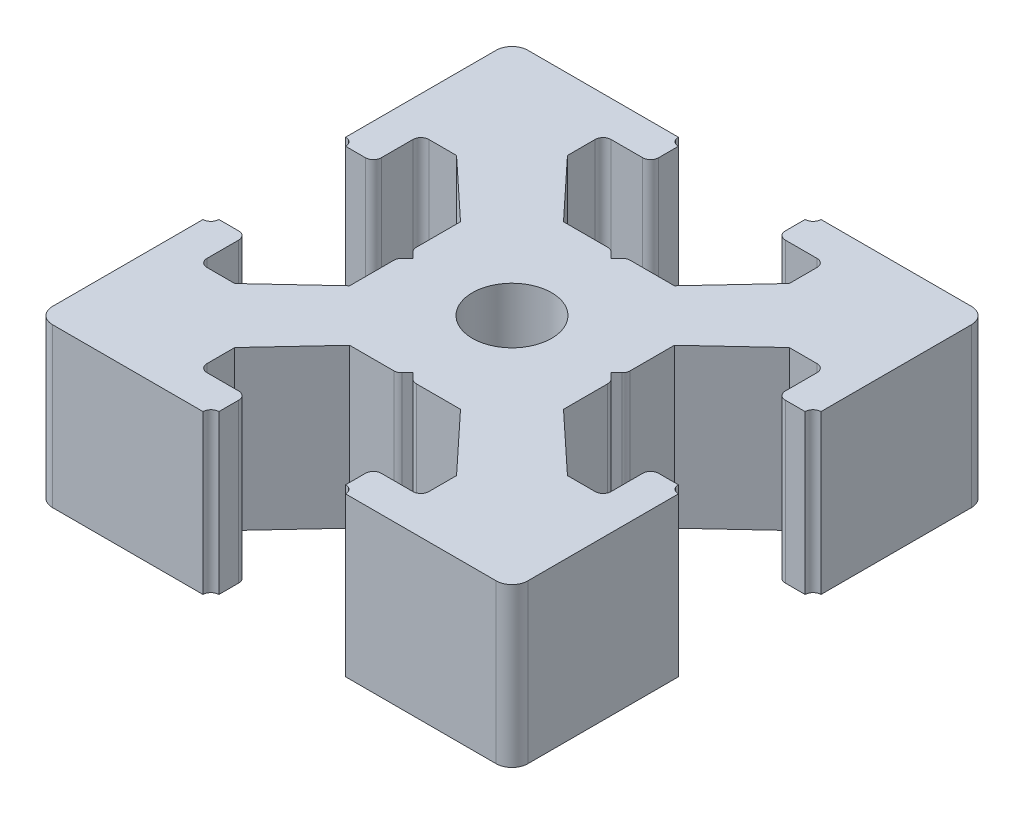
from build123d import *

# Parameters (mm, degrees)
BOSS_EXTRUDE1_DEPTH = 10
FILLET1_R           = 1
SKETCH4_R           = 2.5
CUT_EXTRUDE1_DEPTH  = 11
FILLET2_R           = 0.5


with BuildPart() as part:
    # Sketch3 → Boss-Extrude1 (new body)
    with BuildSketch(Plane(origin=(0, 0, 0), x_dir=(1, 0, 0), z_dir=(0, 1, 0))):
        with BuildLine():
            Line((11, 27.75), (11, 29.5))
            ThreePointArc((11, 29.5), (10.646446609, 29.646446609), (10.5, 30))
            Line((10.5, 30), (0, 30))
            Line((0, 30), (0, 19.5))
            ThreePointArc((0, 19.5), (0.353553391, 19.353553391), (0.5, 19))
            Line((0.5, 19), (2.25, 19))
            Line((2.25, 19), (2.25, 22))
            Line((2.25, 22), (4.5, 22))
            Line((4.5, 22), (8.25, 18.5))
            Line((8.25, 18.5), (8.25, 15.5))
            Line((8.25, 15.5), (8.75, 15))
            Line((8.75, 15), (8.25, 14.5))
            Line((8.25, 14.5), (8.25, 11.5))
            Line((8.25, 11.5), (4.5, 8))
            Line((4.5, 8), (2.25, 8))
            Line((2.25, 8), (2.25, 11))
            Line((2.25, 11), (0.5, 11))
            ThreePointArc((0.5, 11), (0.353553391, 10.646446609), (0, 10.5))
            Line((0, 10.5), (0, 0))
            Line((0, 0), (10.5, 0))
            ThreePointArc((10.5, 0), (10.646446609, 0.353553391), (11, 0.5))
            Line((11, 0.5), (11, 2.25))
            Line((11, 2.25), (8, 2.25))
            Line((8, 2.25), (8, 4.5))
            Line((8, 4.5), (11.5, 8.25))
            Line((11.5, 8.25), (14.5, 8.25))
            Line((14.5, 8.25), (15, 8.75))
            Line((15, 8.75), (15.5, 8.25))
            Line((15.5, 8.25), (18.5, 8.25))
            Line((18.5, 8.25), (22, 4.5))
            Line((22, 4.5), (22, 2.25))
            Line((22, 2.25), (19, 2.25))
            Line((19, 2.25), (19, 0.5))
            ThreePointArc((19, 0.5), (19.353553391, 0.353553391), (19.5, 0))
            Line((19.5, 0), (30, 0))
            Line((30, 0), (30, 10.5))
            ThreePointArc((30, 10.5), (29.646446609, 10.646446609), (29.5, 11))
            Line((29.5, 11), (27.75, 11))
            Line((27.75, 11), (27.75, 8))
            Line((27.75, 8), (25.5, 8))
            Line((25.5, 8), (21.75, 11.5))
            Line((21.75, 11.5), (21.75, 14.5))
            Line((21.75, 14.5), (21.25, 15))
            Line((21.25, 15), (21.75, 15.5))
            Line((21.75, 15.5), (21.75, 18.5))
            Line((21.75, 18.5), (25.5, 22))
            Line((25.5, 22), (27.75, 22))
            Line((27.75, 22), (27.75, 19))
            Line((27.75, 19), (29.5, 19))
            ThreePointArc((29.5, 19), (29.646446609, 19.353553391), (30, 19.5))
            Line((30, 19.5), (30, 30))
            Line((30, 30), (19.5, 30))
            ThreePointArc((19.5, 30), (19.353553391, 29.646446609), (19, 29.5))
            Line((19, 29.5), (19, 27.75))
            Line((19, 27.75), (22, 27.75))
            Line((22, 27.75), (22, 25.5))
            Line((22, 25.5), (18.5, 21.75))
            Line((18.5, 21.75), (15.5, 21.75))
            Line((15.5, 21.75), (15, 21.25))
            Line((15, 21.25), (14.5, 21.75))
            Line((14.5, 21.75), (11.5, 21.75))
            Line((11.5, 21.75), (8, 25.5))
            Line((8, 25.5), (8, 27.75))
            Line((8, 27.75), (11, 27.75))
        make_face()
    extrude(amount=BOSS_EXTRUDE1_DEPTH)

    # Fillet1
    fillet1_edges = [part.edges().sort_by_distance(p)[0] for p in [
        (30, 5, 0),
        (0, 5, 0),
        (0, 5, -30),
        (30, 5, -30),
    ]]
    fillet(fillet1_edges, radius=FILLET1_R)

    # Sketch4 → Cut-Extrude1 (cut, through all)
    with BuildSketch(Plane(origin=(0, 10, 0), x_dir=(1, 0, 0), z_dir=(0, 1, 0))):
        with Locations((15, 15)):
            Circle(SKETCH4_R)
    extrude(amount=-CUT_EXTRUDE1_DEPTH, mode=Mode.SUBTRACT)

    # Fillet2
    fillet2_edges = [part.edges().sort_by_distance(p)[0] for p in [
        (27.75, 5, -19),
        (27.75, 5, -22),
        (21.75, 5, -15.5),
        (21.75, 5, -14.5),
        (27.75, 5, -8),
        (27.75, 5, -11),
        (19, 5, -2.25),
        (22, 5, -2.25),
        (15.5, 5, -8.25),
        (14.5, 5, -8.25),
        (8, 5, -2.25),
        (11, 5, -2.25),
        (2.25, 5, -11),
        (2.25, 5, -8),
        (8.25, 5, -14.5),
        (8.25, 5, -15.5),
        (2.25, 5, -22),
        (2.25, 5, -19),
        (11, 5, -27.75),
        (8, 5, -27.75),
        (14.5, 5, -21.75),
        (15.5, 5, -21.75),
        (22, 5, -27.75),
        (19, 5, -27.75),
    ]]
    fillet(fillet2_edges, radius=FILLET2_R)


solid = part.part
